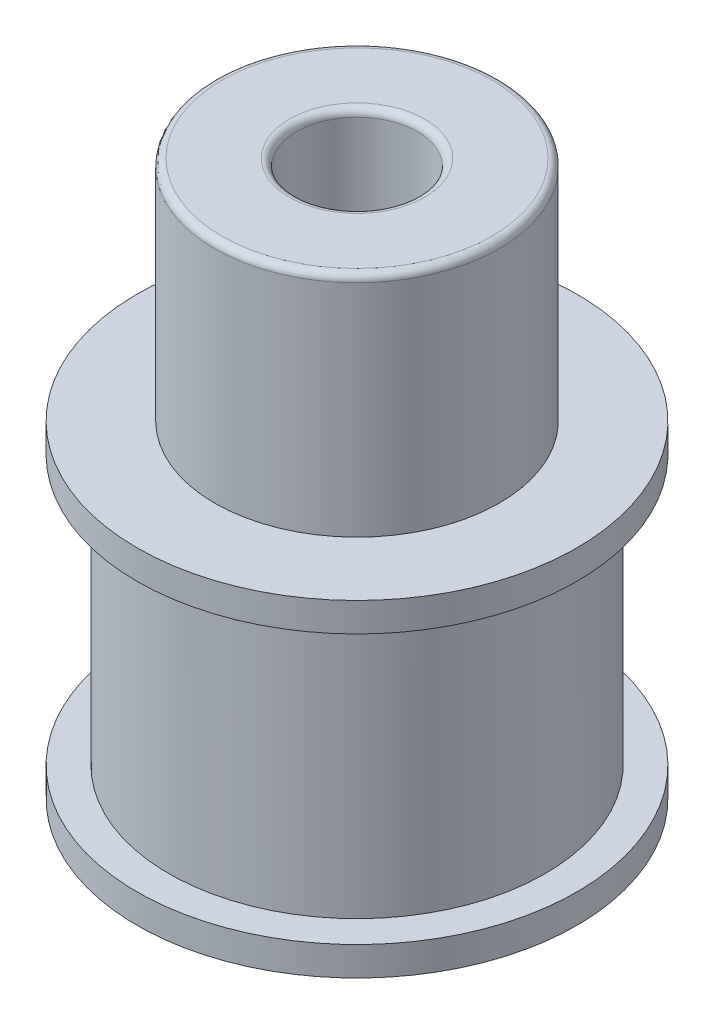
from build123d import *

# Parameters (mm, degrees)
SKETCH1_R           = 9.09
BOSS_EXTRUDE1_DEPTH = 13.52
SKETCH2_R           = 5.885
BOSS_EXTRUDE2_DEPTH = 9.41
SKETCH3_OUTSIDE_W   = 27.07
SKETCH3_OUTSIDE_H   = 27.07
SKETCH3_OUTSIDE_R   = 7.78
CUT_EXTRUDE1_DEPTH  = 12.32
SKETCH4_R           = 9.09
BOSS_EXTRUDE3_DEPTH = 1.2
SKETCH5_R           = 2.5
CUT_EXTRUDE2_DEPTH  = 23.93
FILLET3_R           = 0.3


with BuildPart() as part:
    # Sketch1 → Boss-Extrude1 (new body)
    with BuildSketch(Plane(origin=(0, 0, 0), x_dir=(1, 0, 0), z_dir=(0, 1, 0))):
        Circle(SKETCH1_R)
    extrude(amount=BOSS_EXTRUDE1_DEPTH)

    # Sketch2 → Boss-Extrude2 (add)
    with BuildSketch(Plane(origin=(0, 13.52, 0), x_dir=(1, 0, 0), z_dir=(0, 1, 0))):
        Circle(SKETCH2_R)
    extrude(amount=BOSS_EXTRUDE2_DEPTH)

    # Sketch3 outside → Cut-Extrude1 (cut)
    with BuildSketch(Plane.XZ):
        Rectangle(SKETCH3_OUTSIDE_W, SKETCH3_OUTSIDE_H)
        Circle(SKETCH3_OUTSIDE_R, mode=Mode.SUBTRACT)
    extrude(amount=-CUT_EXTRUDE1_DEPTH, mode=Mode.SUBTRACT)

    # Sketch4 → Boss-Extrude3 (add)
    with BuildSketch(Plane.XZ):
        Circle(SKETCH4_R)
    extrude(amount=-BOSS_EXTRUDE3_DEPTH)

    # Sketch5 → Cut-Extrude2 (cut, through all)
    with BuildSketch(Plane.XZ):
        Circle(SKETCH5_R)
    extrude(amount=-CUT_EXTRUDE2_DEPTH, mode=Mode.SUBTRACT)

    # Fillet3
    fillet3_edges = [part.edges().sort_by_distance(p)[0] for p in [
        (-2.5, 22.93, 0),
        (-2.5, 0, 0),
        (-5.885, 22.93, 0),
    ]]
    fillet(fillet3_edges, radius=FILLET3_R)


solid = part.part
